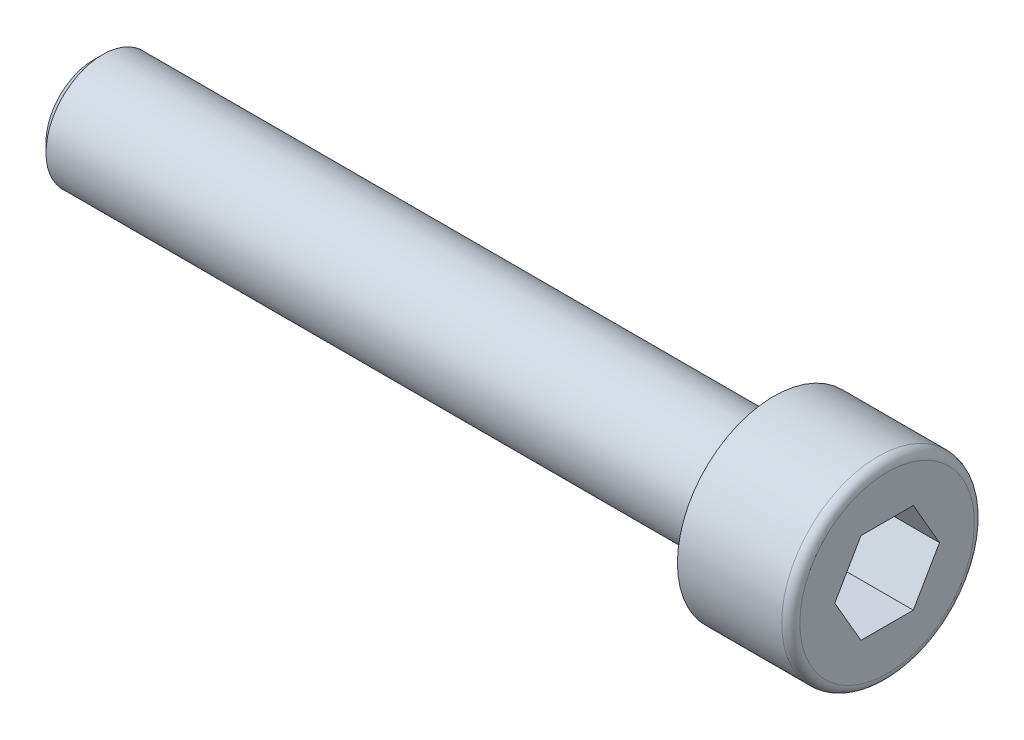
from build123d import *

# Parameters (mm, degrees)
SFAZOWANIE1_SIZE           = 0.4
ZAOKR_GLENIE1_R            = 0.4
WYTNIJ_WYCI_GNI_CIE1_DEPTH = 4


with BuildPart() as part:
    # Szkic1 → Obrót1 (revolve)
    with BuildSketch(Plane.XY):
        Polygon((0, 0), (0, 4.25), (-5, 4.25), (-5, 2.5), (-35, 2.5), (-35, 0), align=None)
    revolve(axis=Axis((-123.158940217, 0, 0), (1, 0, 0)))

    # Sfazowanie1
    sfazowanie1_edges = [part.edges().sort_by_distance(p)[0] for p in [
        (-35, -2.5, 0),
    ]]
    chamfer(sfazowanie1_edges, length=SFAZOWANIE1_SIZE)

    # Zaokrąglenie1
    zaokr_glenie1_edges = [part.edges().sort_by_distance(p)[0] for p in [
        (0, -4.25, 0),
    ]]
    fillet(zaokr_glenie1_edges, radius=ZAOKR_GLENIE1_R)

    # Szkic2 → Wytnij-wyciągnięcie1 (cut)
    with BuildSketch(Plane(origin=(0, 0, 0), x_dir=(0, 0, -1), z_dir=(1, 0, 0))):
        Polygon((2.309401077, 0), (1.154700538, 2), (-1.154700538, 2), (-2.309401077, 0), (-1.154700538, -2), (1.154700538, -2), align=None)
    extrude(amount=-WYTNIJ_WYCI_GNI_CIE1_DEPTH, mode=Mode.SUBTRACT)


solid = part.part
